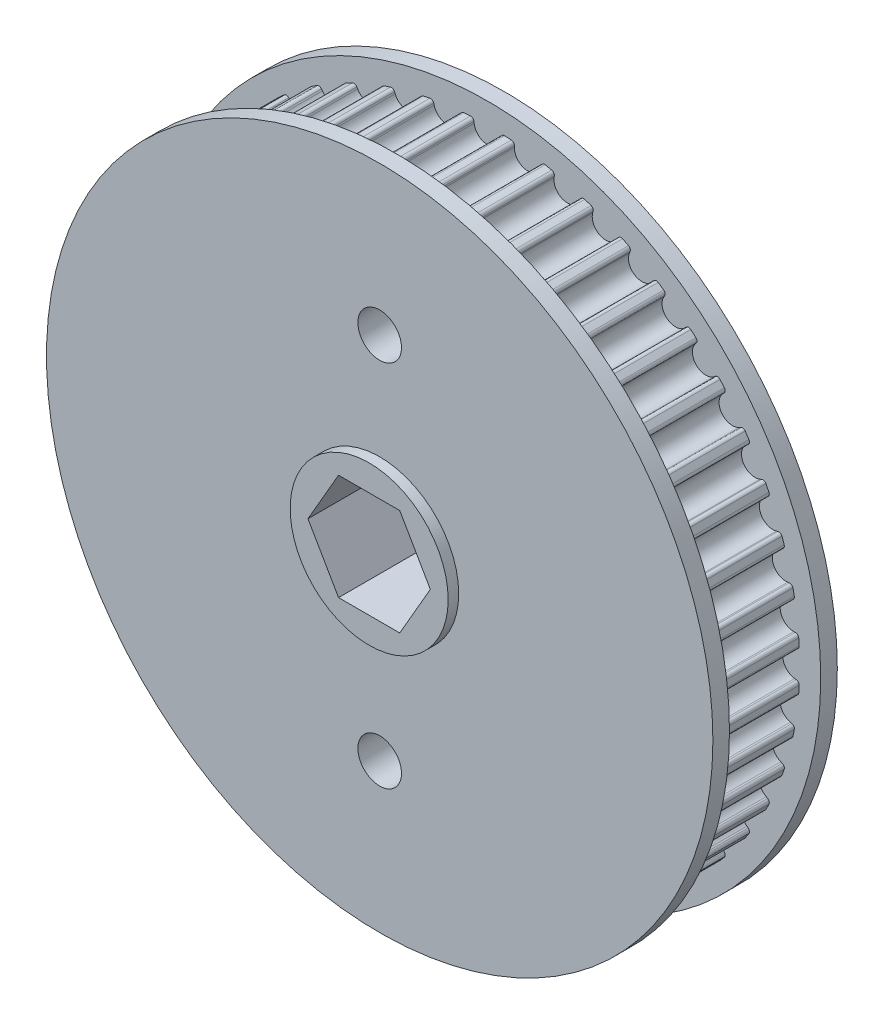
from build123d import *

# Parameters (mm, degrees)
SKETCH2_R                                 = 37.624469958
PULLEY_DEPTH                              = 5.500000049
CUT_TOOTH_DEPTH                           = 5.500000049
BLEND_TOOTH_R                             = 0.4
TOOTH_PATTERN_COUNT                       = 48
BLEND_TOOTH_OF_TOOTH_PATTERN_R            = 0.4
SIDEWALL_START                            = 5.500000049
SKETCH3_R                                 = 40.164469958
SIDEWALL_DEPTH                            = 2.000000064
BEARING_SPACER_MANUAL_SUPPRESS_DEPTH      = 8.770000113
BEARING_SPACER_MANUAL_SUPPRESS_DEPTH_BACK = 8.770000113
SKETCH5_R                                 = 9.525
HEX_SHAFT_DEPTH                           = 63.5
NUMBER_OF_TEETH_DEPTH                     = 3.175
SKETCH9_R                                 = 2.6289
CUT_EXTRUDE4_DEPTH                        = 60.085380742
SKETCH10_R                                = 3.96875
CUT_EXTRUDE5_DEPTH                        = 4.7625
CUT_EXTRUDE6_DEPTH                        = 6.35


with BuildPart() as part:
    # Sketch2 → pulley (new, symmetric)
    with BuildSketch(Plane.XY):
        Circle(SKETCH2_R)
    extrude(amount=PULLEY_DEPTH, both=True)

    # tooth → cut tooth (cut, symmetric)
    with BuildSketch(Plane.XY):
        with BuildLine():
            Line((-2.132711961, 41.260062405), (-1.612887548, 37.026432307))
            ThreePointArc((-1.612887548, 37.026432307), (0, 35.599469944), (1.612887548, 37.026432307))
            Line((1.612887548, 37.026432307), (2.132711961, 41.260062405))
            Line((2.132711961, 41.260062405), (-2.132711961, 41.260062405))
        make_face()
    cut_tooth = extrude(amount=CUT_TOOTH_DEPTH, both=True, mode=Mode.SUBTRACT)

    # blend tooth
    blend_tooth_edges = [part.edges().sort_by_distance(p)[0] for p in [
        (1.681700362, 37.5868677, 0),
        (-1.681700362, 37.5868677, 0),
    ]]
    fillet(blend_tooth_edges, radius=BLEND_TOOTH_R)

    # tooth pattern: cut tooth ×48 about axis
    tooth_pattern_axis = Axis((0, 0, 5.500000049), (0, 0, -1))
    for i in range(1, TOOTH_PATTERN_COUNT):
        add(cut_tooth.rotate(tooth_pattern_axis, i * 360 / TOOTH_PATTERN_COUNT), mode=Mode.SUBTRACT)

    # blend tooth of tooth pattern
    blend_tooth_of_tooth_pattern_edges = [part.edges().sort_by_distance(p)[0] for p in [
        (6.5733839, 37.045800892, 0),
        (3.238757536, 37.484812781, 0),
        (11.352595018, 35.870870159, 0),
        (8.103799395, 36.741382323, 0),
        (15.937560087, 34.082178893, 0),
        (12.830182999, 35.369296626, 0),
        (20.249829085, 31.710332096, 0),
        (17.337038615, 33.392032458, 0),
        (24.215617893, 28.795912726, 0),
        (21.547252694, 30.843421356, 0),
        (27.767070764, 25.388787305, 0),
        (25.388787305, 27.767070764, 0),
        (30.843421356, 21.547252694, 0),
        (28.795912726, 24.215617893, 0),
        (33.392032458, 17.337038615, 0),
        (31.710332096, 20.249829085, 0),
        (35.369296626, 12.830182999, 0),
        (34.082178893, 15.937560087, 0),
        (36.741382323, 8.103799395, 0),
        (35.870870159, 11.352595018, 0),
        (37.484812781, 3.238757536, 0),
        (37.045800892, 6.5733839, 0),
        (37.5868677, -1.681700362, 0),
        (37.5868677, 1.681700362, 0),
        (37.045800892, -6.5733839, 0),
        (37.484812781, -3.238757536, 0),
        (35.870870159, -11.352595018, 0),
        (36.741382323, -8.103799395, 0),
        (34.082178893, -15.937560087, 0),
        (35.369296626, -12.830182999, 0),
        (31.710332096, -20.249829085, 0),
        (33.392032458, -17.337038615, 0),
        (28.795912726, -24.215617893, 0),
        (30.843421356, -21.547252694, 0),
        (25.388787305, -27.767070764, 0),
        (27.767070764, -25.388787305, 0),
        (21.547252694, -30.843421356, 0),
        (24.215617893, -28.795912726, 0),
        (17.337038615, -33.392032458, 0),
        (20.249829085, -31.710332096, 0),
        (12.830182999, -35.369296626, 0),
        (15.937560087, -34.082178893, 0),
        (8.103799395, -36.741382323, 0),
        (11.352595018, -35.870870159, 0),
        (3.238757536, -37.484812781, 0),
        (6.5733839, -37.045800892, 0),
        (-1.681700362, -37.5868677, 0),
        (1.681700362, -37.5868677, 0),
        (-6.5733839, -37.045800892, 0),
        (-3.238757536, -37.484812781, 0),
        (-11.352595018, -35.870870159, 0),
        (-8.103799395, -36.741382323, 0),
        (-15.937560087, -34.082178893, 0),
        (-12.830182999, -35.369296626, 0),
        (-20.249829085, -31.710332096, 0),
        (-17.337038615, -33.392032458, 0),
        (-24.215617893, -28.795912726, 0),
        (-21.547252694, -30.843421356, 0),
        (-27.767070764, -25.388787305, 0),
        (-25.388787305, -27.767070764, 0),
        (-30.843421356, -21.547252694, 0),
        (-28.795912726, -24.215617893, 0),
        (-33.392032458, -17.337038615, 0),
        (-31.710332096, -20.249829085, 0),
        (-35.369296626, -12.830182999, 0),
        (-34.082178893, -15.937560087, 0),
        (-36.741382323, -8.103799395, 0),
        (-35.870870159, -11.352595018, 0),
        (-37.484812781, -3.238757536, 0),
        (-37.045800892, -6.5733839, 0),
        (-37.5868677, 1.681700362, 0),
        (-37.5868677, -1.681700362, 0),
        (-37.045800892, 6.5733839, 0),
        (-37.484812781, 3.238757536, 0),
        (-35.870870159, 11.352595018, 0),
        (-36.741382323, 8.103799395, 0),
        (-34.082178893, 15.937560087, 0),
        (-35.369296626, 12.830182999, 0),
        (-31.710332096, 20.249829085, 0),
        (-33.392032458, 17.337038615, 0),
        (-28.795912726, 24.215617893, 0),
        (-30.843421356, 21.547252694, 0),
        (-25.388787305, 27.767070764, 0),
        (-27.767070764, 25.388787305, 0),
        (-21.547252694, 30.843421356, 0),
        (-24.215617893, 28.795912726, 0),
        (-17.337038615, 33.392032458, 0),
        (-20.249829085, 31.710332096, 0),
        (-12.830182999, 35.369296626, 0),
        (-15.937560087, 34.082178893, 0),
        (-8.103799395, 36.741382323, 0),
        (-11.352595018, 35.870870159, 0),
        (-3.238757536, 37.484812781, 0),
        (-6.5733839, 37.045800892, 0),
    ]]
    fillet(blend_tooth_of_tooth_pattern_edges, radius=BLEND_TOOTH_OF_TOOTH_PATTERN_R)

    # Sketch3 → sidewall (add)
    with BuildSketch(Plane.XY.offset(SIDEWALL_START)):
        Circle(SKETCH3_R)
    sidewall = extrude(amount=SIDEWALL_DEPTH)

    # mirror sidewall: sidewall across plane
    add(sidewall.mirror(Plane.XY))

    # Sketch5 → bearing spacer _Manual Suppress (add, two sides: drawn at the far end of the back side and taken through both)
    with BuildSketch(Plane.XY.offset(-BEARING_SPACER_MANUAL_SUPPRESS_DEPTH_BACK)):
        Circle(SKETCH5_R)
    extrude(amount=BEARING_SPACER_MANUAL_SUPPRESS_DEPTH + BEARING_SPACER_MANUAL_SUPPRESS_DEPTH_BACK)

    # Sketch4 → hex shaft (cut, symmetric)
    with BuildSketch(Plane.XY):
        Polygon((3.688171255, 6.3881), (-3.688171255, 6.3881), (-7.376342509, 0), (-3.688171255, -6.3881), (3.688171255, -6.3881), (7.376342509, 0), align=None)
    extrude(amount=HEX_SHAFT_DEPTH, both=True, mode=Mode.SUBTRACT)

    # Sketch8 → number of teeth (cut)
    # profile 1 of 2: a face of its own
    with BuildSketch(Plane(origin=(0, 0, -7.500000113), x_dir=(-1, 0, 0), z_dir=(0, 0, -1))):
        Polygon((13.735336538, 1.788561699), (13.729727564, 1.859375), (16.155608974, 2.046574519), (16.123357372, 2.467948718), (16.457091346, 2.493189103), (16.489342949, 2.071814904), (17.2984375, 2.134214744), (17.325080128, 1.786458333), (16.515985577, 1.724058494), (16.643589744, 0.060997596), align=None)
        Polygon((16.182251603, 1.698818109), (14.731630609, 1.586638622), (16.260777244, 0.674479167), align=None, mode=Mode.SUBTRACT)
    # profile 2 of 2: a face of its own
    with BuildSketch(Plane(origin=(0, 0, -7.500000113), x_dir=(-1, 0, 0), z_dir=(0, 0, -1))):
        with BuildLine():
            add(Edge.make_bspline(
                [(14.97427651, 4.054227706), (14.981872025, 4.085174637), (14.99676406, 4.145850283), (15.024439111, 4.232890561), (15.053465846, 4.314908448), (15.086656322, 4.390603484), (15.122053788, 4.460861006), (15.161086597, 4.525065518), (15.202031515, 4.584031287), (15.246618977, 4.637323528), (15.29488292, 4.684644725), (15.344320938, 4.729542366), (15.398129511, 4.768804738), (15.454790087, 4.803657635), (15.514312228, 4.834776247), (15.576435391, 4.86222559), (15.641947337, 4.884719287), (15.68699472, 4.896122764), (15.709753272, 4.901883956)],
                knots=[0, 0, 0, 0, 1.283629045, 2.516728455, 3.678508752, 4.787688352, 5.844795931, 6.846111966, 7.812775132, 8.735169277, 9.640777987, 10.53465769, 11.423662825, 12.320068806, 13.213055175, 14.128113294, 15.054297294, 16, 16, 16, 16], degree=3))
            add(Edge.make_bspline(
                [(15.709753272, 4.901883956), (15.742133278, 4.908833249), (15.806004987, 4.922541191), (15.902807741, 4.931829604), (15.998526577, 4.933671218), (16.093343161, 4.925710309), (16.187167322, 4.909453028), (16.279969331, 4.884987411), (16.371659175, 4.851138747), (16.430730661, 4.822461016), (16.460654715, 4.807933636)],
                knots=[0, 0, 0, 0, 1.026855433, 2.025540464, 3.011906209, 3.994157959, 4.972977128, 5.963307028, 6.968265152, 8, 8, 8, 8], degree=3))
            add(Edge.make_bspline(
                [(16.460654715, 4.807933636), (16.496280384, 4.78802382), (16.567000778, 4.748500914), (16.662613242, 4.673719853), (16.748900896, 4.588615527), (16.826889125, 4.493090991), (16.892900994, 4.384531368), (16.951402673, 4.266520916), (17.000406148, 4.137186633), (17.023624229, 4.045850062), (17.035574586, 3.998839084)],
                knots=[0, 0, 0, 0, 0.953904672, 1.893592855, 2.829501443, 3.786145899, 4.771105661, 5.795936537, 6.865567467, 8, 8, 8, 8], degree=3))
            add(Edge.make_bspline(
                [(17.035574586, 3.998839084), (17.045140988, 3.953155733), (17.063729465, 3.864388402), (17.079520545, 3.73284414), (17.082491745, 3.607223276), (17.073570635, 3.487637766), (17.052929751, 3.373830055), (17.018708979, 3.26677375), (16.973876707, 3.165163135), (16.916062808, 3.071533185), (16.850903531, 2.98520352), (16.781694642, 2.906217957), (16.707595115, 2.836455885), (16.629537708, 2.77506924), (16.547267545, 2.722398269), (16.461019419, 2.677801517), (16.370499345, 2.641447429), (16.307321043, 2.625131004), (16.275558561, 2.616928027)],
                knots=[0, 0, 0, 0, 1.267948699, 2.463751401, 3.594491168, 4.677290754, 5.71737979, 6.729700859, 7.724681322, 8.727816838, 9.712201262, 10.661544398, 11.578051779, 12.473726726, 13.356337346, 14.228350968, 15.109314924, 16, 16, 16, 16], degree=3))
            add(Edge.make_bspline(
                [(16.275558561, 2.616928027), (16.228998579, 2.607719037), (16.137413263, 2.589604592), (15.997961216, 2.588500585), (15.861338135, 2.606475268), (15.750344906, 2.639457205), (15.663335709, 2.676820843), (15.597733889, 2.711867621), (15.532327123, 2.753635922), (15.466846309, 2.80146348), (15.40159639, 2.856379891), (15.336655712, 2.918296999), (15.271043565, 2.986323506), (15.22922084, 3.035494782), (15.207750067, 3.060738123)],
                knots=[0, 0, 0, 0, 1.390601632, 2.735368148, 4.071356721, 5.423661498, 6.118175004, 6.848590313, 7.604152734, 8.394511903, 9.227206109, 10.10555927, 11.027440076, 12, 12, 12, 12], degree=3))
            add(Edge.make_bspline(
                [(15.207750067, 3.060738123), (15.194907453, 3.016253919), (15.170038677, 2.930113541), (15.118228377, 2.809584022), (15.053273929, 2.703711989), (14.97786772, 2.611794902), (14.893440812, 2.534282276), (14.801302355, 2.471022256), (14.701630528, 2.422177561), (14.630643923, 2.402472052), (14.594969619, 2.392569052)],
                knots=[0, 0, 0, 0, 1.162316173, 2.250739494, 3.283735632, 4.272149979, 5.227787307, 6.152655419, 7.071617353, 8, 8, 8, 8], degree=3))
            add(Edge.make_bspline(
                [(14.594969619, 2.392569052), (14.557943387, 2.385538241), (14.483419415, 2.371387083), (14.367653956, 2.371825779), (14.249589362, 2.388277848), (14.130736411, 2.421108985), (14.014485703, 2.469858581), (13.905231854, 2.535002355), (13.80365833, 2.614962377), (13.712974764, 2.710340062), (13.631898611, 2.816438167), (13.565916646, 2.93293464), (13.510635471, 3.056460228), (13.487632241, 3.143997528), (13.475979234, 3.18834229)],
                knots=[0, 0, 0, 0, 0.890462119, 1.79226381, 2.724899484, 3.70602731, 4.702723426, 5.699926114, 6.708254535, 7.752945091, 8.807433937, 9.860775628, 10.916308895, 12, 12, 12, 12], degree=3))
            add(Edge.make_bspline(
                [(13.475979234, 3.18834229), (13.467376636, 3.23212611), (13.450418875, 3.318434408), (13.444671053, 3.449771076), (13.454356058, 3.579513402), (13.480405568, 3.706908519), (13.521114614, 3.828914744), (13.57718315, 3.942510337), (13.647056211, 4.046210326), (13.729637097, 4.139278157), (13.822287009, 4.219410465), (13.922349317, 4.285478946), (14.028442191, 4.337337632), (14.103778286, 4.358018152), (14.141343817, 4.36833027)],
                knots=[0, 0, 0, 0, 1.068008789, 2.105298713, 3.13874148, 4.178854665, 5.21311653, 6.212445475, 7.204987916, 8.200732546, 9.185407109, 10.131352365, 11.068219002, 12, 12, 12, 12], degree=3))
            add(Edge.make_bspline(
                [(14.141343817, 4.36833027), (14.179053901, 4.375815027), (14.253049077, 4.390501707), (14.36530831, 4.392159465), (14.474426336, 4.377252685), (14.580935715, 4.346137331), (14.68413775, 4.297286284), (14.785014975, 4.232876168), (14.883246354, 4.151404298), (14.943183738, 4.087419889), (14.97427651, 4.054227706)],
                knots=[0, 0, 0, 0, 0.980916575, 1.924766195, 2.853067469, 3.786714036, 4.748663889, 5.761024548, 6.838522012, 8, 8, 8, 8], degree=3))
        make_face()
        with BuildLine():
            add(Edge.make_bspline(
                [(13.809012086, 3.249339886), (13.814689935, 3.226784377), (13.825893793, 3.182276553), (13.849236952, 3.118822404), (13.87640502, 3.059176972), (13.909316225, 3.004655188), (13.944439841, 2.952808511), (13.986001555, 2.906633449), (14.030499996, 2.86324013), (14.08038877, 2.826238868), (14.131779679, 2.792855332), (14.185253352, 2.766705446), (14.238591421, 2.744789747), (14.293190407, 2.731164982), (14.348090787, 2.722348488), (14.40384771, 2.720424493), (14.460346676, 2.724392587), (14.497580578, 2.732175673), (14.516443978, 2.736118732)],
                knots=[0, 0, 0, 0, 1.146144182, 2.261637559, 3.328884468, 4.372412516, 5.398616731, 6.411141954, 7.430008392, 8.457958128, 9.468185512, 10.447372873, 11.388948839, 12.305728033, 13.215162694, 14.126202198, 15.050698585, 16, 16, 16, 16], degree=3))
            add(Edge.make_bspline(
                [(14.516443978, 2.736118732), (14.535051472, 2.741052004), (14.571803063, 2.750795691), (14.624442799, 2.773191971), (14.674155755, 2.801047841), (14.720829729, 2.83538167), (14.765058458, 2.874699126), (14.806869144, 2.919680455), (14.844313015, 2.971609898), (14.880033053, 3.02738932), (14.910177106, 3.087258189), (14.936085113, 3.148102063), (14.953969667, 3.210377382), (14.966945699, 3.272914381), (14.973305554, 3.336370987), (14.972903008, 3.400409137), (14.9679884, 3.465367755), (14.958664969, 3.508133722), (14.953943978, 3.529788604)],
                knots=[0, 0, 0, 0, 0.923644501, 1.824286654, 2.739088969, 3.655198981, 4.601419923, 5.578565248, 6.597874215, 7.672372332, 8.756793233, 9.81373214, 10.843801717, 11.863110684, 12.878455863, 13.899987702, 14.936642377, 16, 16, 16, 16], degree=3))
            add(Edge.make_bspline(
                [(14.953943978, 3.529788604), (14.946533527, 3.557396806), (14.931871338, 3.612021913), (14.89633301, 3.689284686), (14.852121158, 3.761982213), (14.798122029, 3.8288892), (14.736935769, 3.888953192), (14.669174493, 3.94033378), (14.594875259, 3.980126014), (14.516656642, 4.010346665), (14.436841686, 4.029325451), (14.358123612, 4.039958036), (14.2812038, 4.038976786), (14.231697663, 4.029473666), (14.207249266, 4.024780591)],
                knots=[0, 0, 0, 0, 1.036734501, 2.05126474, 3.076254331, 4.120986868, 5.165546937, 6.184259654, 7.198505712, 8.216970796, 9.221757893, 10.171532618, 11.09701909, 12, 12, 12, 12], degree=3))
            add(Edge.make_bspline(
                [(14.207249266, 4.024780591), (14.190577247, 4.020134066), (14.15722105, 4.010837628), (14.108659493, 3.992206069), (14.062865673, 3.967160459), (14.019214555, 3.937563972), (13.977676385, 3.903244291), (13.939071977, 3.863258347), (13.901785557, 3.819345613), (13.867613139, 3.770388391), (13.837284141, 3.717443327), (13.813363106, 3.660512434), (13.796439116, 3.599958989), (13.786128433, 3.536229844), (13.781954867, 3.469066739), (13.784362882, 3.398708115), (13.792501473, 3.324733972), (13.803400243, 3.274965814), (13.809012086, 3.249339886)],
                knots=[0, 0, 0, 0, 0.853111054, 1.706844363, 2.557461846, 3.420321289, 4.304008488, 5.208410788, 6.157018904, 7.14154499, 8.147679344, 9.159865292, 10.177545182, 11.240215971, 12.337007579, 13.489747672, 14.707455784, 16, 16, 16, 16], degree=3))
        make_face(mode=Mode.SUBTRACT)
        with BuildLine():
            add(Edge.make_bspline(
                [(15.258931958, 3.606912001), (15.266447635, 3.578508795), (15.281228117, 3.522650476), (15.310447432, 3.442247316), (15.347499942, 3.367803569), (15.389420255, 3.297575952), (15.438714131, 3.233263729), (15.493848368, 3.173841024), (15.554962947, 3.119571647), (15.62208401, 3.07185768), (15.692000142, 3.029904383), (15.763976513, 2.996130896), (15.836476351, 2.969897067), (15.909545238, 2.951698596), (15.983289983, 2.940671688), (16.057582933, 2.939043458), (16.132683296, 2.944070025), (16.181932157, 2.954499834), (16.206848625, 2.959776584)],
                knots=[0, 0, 0, 0, 1.105679788, 2.174452213, 3.213112313, 4.231494197, 5.248469239, 6.256885277, 7.278946175, 8.318983784, 9.352452511, 10.344153314, 11.306949178, 12.250010362, 13.174381265, 14.107252693, 15.042402704, 16, 16, 16, 16], degree=3))
            add(Edge.make_bspline(
                [(16.206848625, 2.959776584), (16.237308555, 2.968244545), (16.29793393, 2.985098598), (16.383457017, 3.026140642), (16.463379581, 3.078478136), (16.536840969, 3.142264724), (16.601741908, 3.215759129), (16.65509312, 3.298591999), (16.696725421, 3.388962592), (16.725839935, 3.486962663), (16.743634006, 3.590785198), (16.747159946, 3.699796813), (16.739263925, 3.813284573), (16.723330688, 3.88913716), (16.715161926, 3.928025783)],
                knots=[0, 0, 0, 0, 0.929496503, 1.85000671, 2.77960512, 3.735851028, 4.706330237, 5.656987574, 6.626978615, 7.626311643, 8.659297549, 9.719951052, 10.831048891, 12, 12, 12, 12], degree=3))
            add(Edge.make_bspline(
                [(16.715161926, 3.928025783), (16.707495303, 3.958091378), (16.692572736, 4.016612038), (16.662041159, 4.100174079), (16.625711959, 4.177044425), (16.584055003, 4.248174731), (16.53652135, 4.312736196), (16.48273444, 4.370637666), (16.42355317, 4.422195746), (16.359004634, 4.466697937), (16.291821164, 4.50476817), (16.223255088, 4.536316495), (16.153751544, 4.559171199), (16.083631259, 4.575652827), (16.012690014, 4.584895706), (15.940997937, 4.586242535), (15.868623147, 4.579907375), (15.820923328, 4.570250881), (15.796692375, 4.565345495)],
                knots=[0, 0, 0, 0, 1.191716326, 2.319595803, 3.412281053, 4.454998395, 5.482404604, 6.486466645, 7.485899329, 8.492368235, 9.493776044, 10.450326301, 11.387498684, 12.3002568, 13.214780407, 14.13097808, 15.050558594, 16, 16, 16, 16], degree=3))
            add(Edge.make_bspline(
                [(15.796692375, 4.565345495), (15.773636989, 4.559038371), (15.727918034, 4.54653131), (15.662267425, 4.519544385), (15.600465877, 4.485867744), (15.542344987, 4.44523459), (15.487454043, 4.398401906), (15.437080399, 4.343812478), (15.389753735, 4.283186668), (15.346923379, 4.216500878), (15.309256728, 4.146159618), (15.279553255, 4.072963447), (15.257209331, 3.998533806), (15.241270257, 3.9228215), (15.234701628, 3.845434588), (15.23452537, 3.767068279), (15.242182703, 3.686945552), (15.253276486, 3.633935743), (15.258931958, 3.606912001)],
                knots=[0, 0, 0, 0, 0.942507252, 1.868996994, 2.793419035, 3.714384591, 4.662649314, 5.63482809, 6.640207697, 7.694114158, 8.758459566, 9.784272062, 10.805389548, 11.821832176, 12.831264046, 13.864140795, 14.91116552, 16, 16, 16, 16], degree=3))
        make_face(mode=Mode.SUBTRACT)
    extrude(amount=-NUMBER_OF_TEETH_DEPTH, mode=Mode.SUBTRACT)

    # Sketch9 → Cut-Extrude4 (cut, through all)
    with BuildSketch(Plane(origin=(0, 0, -7.500000113), x_dir=(-1, 0, 0), z_dir=(0, 0, -1))):
        with Locations((0, -22.225)):
            Circle(SKETCH9_R)
        with Locations((0, 22.225)):
            Circle(SKETCH9_R)
    extrude(amount=-CUT_EXTRUDE4_DEPTH, mode=Mode.SUBTRACT)

    # Sketch10 → Cut-Extrude5 (cut)
    with BuildSketch(Plane(origin=(0, 0, -7.500000113), x_dir=(-1, 0, 0), z_dir=(0, 0, -1))):
        with Locations((0, -22.225)):
            Circle(SKETCH10_R)
    extrude(amount=-CUT_EXTRUDE5_DEPTH, mode=Mode.SUBTRACT)

    # Sketch11 → Cut-Extrude6 (cut)
    with BuildSketch(Plane(origin=(0, 0, -7.500000113), x_dir=(-1, 0, 0), z_dir=(0, 0, -1))):
        Polygon((-2.749630657, 17.4625), (2.749630657, 17.4625), (5.499261314, 22.225), (2.749630657, 26.9875), (-2.749630657, 26.9875), (-5.499261314, 22.225), align=None)
    extrude(amount=-CUT_EXTRUDE6_DEPTH, mode=Mode.SUBTRACT)


solid = part.part
